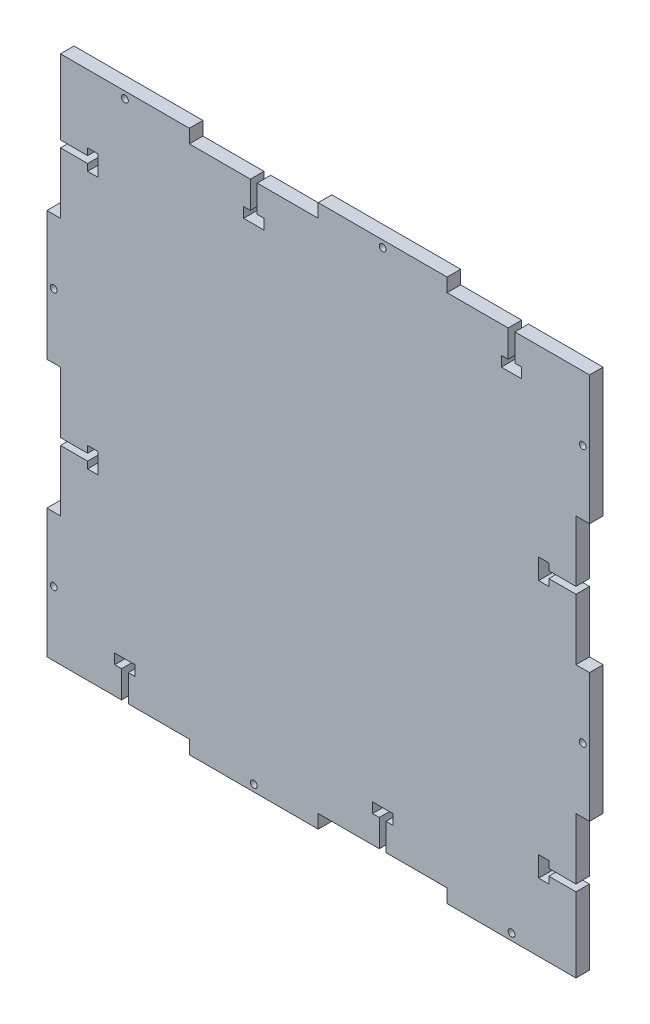
from build123d import *

# Parameters (mm, degrees)
BOSS_EXTRUDE1_DEPTH = 3.175
SKETCH2_R           = 0.79375
CUT_EXTRUDE1_DEPTH  = 90.858670283


with BuildPart() as part:
    # Sketch1 → Boss-Extrude1 (new body)
    with BuildSketch(Plane.XY):
        Polygon((-60.325, 60.325), (-60.325, 63.5), (-30.1625, 63.5), (-30.1625, 60.325), (0, 60.325), (0, 63.5), (30.1625, 63.5), (30.1625, 60.325), (60.325, 60.325), (63.5, 60.325), (63.5, 30.1625), (60.325, 30.1625), (60.325, 0), (63.5, 0), (63.5, -30.1625), (60.325, -30.1625), (60.325, -60.325), (60.325, -63.5), (30.1625, -63.5), (30.1625, -60.325), (0, -60.325), (0, -63.5), (-30.1625, -63.5), (-30.1625, -60.325), (-60.325, -60.325), (-63.5, -60.325), (-63.5, -30.1625), (-60.325, -30.1625), (-60.325, 0), (-63.5, 0), (-63.5, 30.1625), (-60.325, 30.1625), align=None)
    extrude(amount=BOSS_EXTRUDE1_DEPTH)

    # Sketch2 → Cut-Extrude1 (cut, through all)
    with BuildSketch(Plane.XY.offset(3.175)):
        Polygon((-14.2875, 53.975), (-14.2875, 60.325), (-15.875, 60.325), (-15.875, 53.975), (-17.4625, 53.975), (-17.4625, 51.59375), (-12.7, 51.59375), (-12.7, 53.975), align=None)
        Polygon((-53.975, 46.0375), (-60.325, 46.0375), (-60.325, 44.45), (-53.975, 44.45), (-53.975, 42.8625), (-51.59375, 42.8625), (-51.59375, 47.625), (-53.975, 47.625), align=None)
        Polygon((46.0375, 60.325), (44.45, 60.325), (44.45, 53.975), (42.8625, 53.975), (42.8625, 51.59375), (47.625, 51.59375), (47.625, 53.975), (46.0375, 53.975), align=None)
        Polygon((60.325, 14.2875), (60.325, 15.875), (53.975, 15.875), (53.975, 17.4625), (51.59375, 17.4625), (51.59375, 12.7), (53.975, 12.7), (53.975, 14.2875), align=None)
        Polygon((-53.975, -14.2875), (-60.325, -14.2875), (-60.325, -15.875), (-53.975, -15.875), (-53.975, -17.4625), (-51.59375, -17.4625), (-51.59375, -12.7), (-53.975, -12.7), align=None)
        Polygon((-46.0375, -53.975), (-46.0375, -60.325), (-44.45, -60.325), (-44.45, -53.975), (-42.8625, -53.975), (-42.8625, -51.59375), (-47.625, -51.59375), (-47.625, -53.975), align=None)
        Polygon((60.325, -46.0375), (60.325, -44.45), (53.975, -44.45), (53.975, -42.8625), (51.59375, -42.8625), (51.59375, -47.625), (53.975, -47.625), (53.975, -46.0375), align=None)
        Polygon((14.2875, -60.325), (15.875, -60.325), (15.875, -53.975), (17.4625, -53.975), (17.4625, -51.59375), (12.7, -51.59375), (12.7, -53.975), (14.2875, -53.975), align=None)
        with Locations((-45.24375, 61.9125)):
            Circle(SKETCH2_R)
        with Locations((15.08125, 61.9125)):
            Circle(SKETCH2_R)
        with Locations((61.9125, 45.24375)):
            Circle(SKETCH2_R)
        with Locations((61.9125, -15.08125)):
            Circle(SKETCH2_R)
        with Locations((45.24375, -61.9125)):
            Circle(SKETCH2_R)
        with Locations((-15.08125, -61.9125)):
            Circle(SKETCH2_R)
        with Locations((-61.9125, -45.24375)):
            Circle(SKETCH2_R)
        with Locations((-61.9125, 15.08125)):
            Circle(SKETCH2_R)
    extrude(amount=-CUT_EXTRUDE1_DEPTH, mode=Mode.SUBTRACT)


solid = part.part
